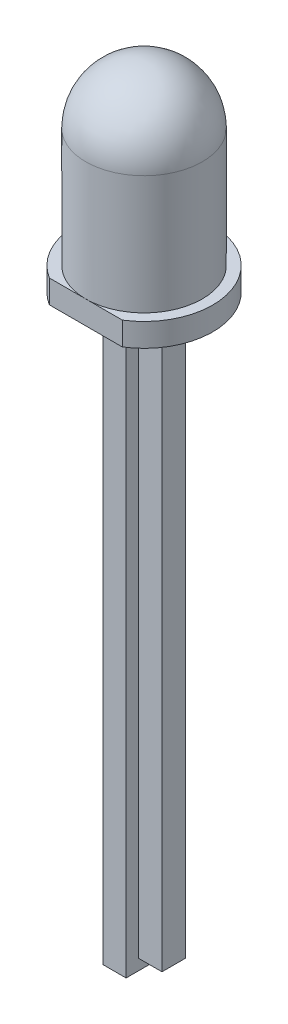
from build123d import *

# Parameters (mm, degrees)
SKETCH1_W           = 2.54
SKETCH1_H           = 1
BASE_EXTRUDE_DEPTH  = 0.381
SKETCH2_W           = 1
SKETCH2_H           = 1
BOSS_EXTRUDE1_DEPTH = 24
SKETCH7_W           = 1
SKETCH7_H           = 1
BOSS_EXTRUDE4_DEPTH = 1
FILLET5_R           = 0.254
BOSS_EXTRUDE2_DEPTH = 1
SKETCH4_R           = 2.5
BOSS_EXTRUDE3_DEPTH = 7.6
FILLET4_R           = 2.5
SKETCH6_W           = 0.032
SKETCH6_H           = 0.381
CUT_EXTRUDE1_DEPTH  = 4.45


with BuildPart() as part:
    # Sketch1 → Base-Extrude (new body)
    with BuildSketch(Plane(origin=(0, 0, 0), x_dir=(1, 0, 0), z_dir=(0, 1, 0))):
        with Locations((0.77, 0)):
            Rectangle(SKETCH1_W, SKETCH1_H)
    extrude(amount=BASE_EXTRUDE_DEPTH)

    # Sketch2 → Boss-Extrude1 (add)
    with BuildSketch(Plane.XZ):
        Rectangle(SKETCH2_W, SKETCH2_H)
        with Locations((1.54, 0)):
            Rectangle(SKETCH2_W, SKETCH2_H)
    extrude(amount=BOSS_EXTRUDE1_DEPTH)

    # Sketch7 → Boss-Extrude4 (add)
    with BuildSketch(Plane.XZ.offset(24)):
        Rectangle(SKETCH7_W, SKETCH7_H)
    extrude(amount=BOSS_EXTRUDE4_DEPTH)

    # Fillet5
    fillet5_edges = [part.edges().sort_by_distance(p)[0] for p in [
        (2.04, 0.381, 0),
        (0.5, 0, 0),
        (1.04, 0, 0),
        (-0.5, 0.381, 0),
    ]]
    fillet(fillet5_edges, radius=FILLET5_R)

    # Sketch3 → Boss-Extrude2 (add)
    with BuildSketch(Plane(origin=(0, 0.381, 0), x_dir=(-1, 0, 0), z_dir=(0, 1, 0))):
        with BuildLine():
            Line((-2.336045976, 2.5), (0.796045976, 2.5))
            ThreePointArc((0.796045976, 2.5), (-0.77, -2.95), (-2.336045976, 2.5))
        make_face()
    extrude(amount=BOSS_EXTRUDE2_DEPTH)

    # Sketch4 → Boss-Extrude3 (add)
    with BuildSketch(Plane(origin=(0, 1.381, 0), x_dir=(-1, 0, 0), z_dir=(0, 1, 0))):
        with Locations((-0.77, 0)):
            Circle(SKETCH4_R)
    extrude(amount=BOSS_EXTRUDE3_DEPTH)

    # Fillet4
    fillet4_edges = [part.edges().sort_by_distance(p)[0] for p in [
        (3.27, 8.981, 0),
    ]]
    fillet(fillet4_edges, radius=FILLET4_R)

    # Sketch6 → Cut-Extrude1 (cut, through all)
    with BuildSketch(Plane.XY.offset(0.5)):
        with Locations((0.77, 0.1905)):
            Rectangle(SKETCH6_W, SKETCH6_H)
    extrude(amount=-CUT_EXTRUDE1_DEPTH, mode=Mode.SUBTRACT)


solid = part.part
